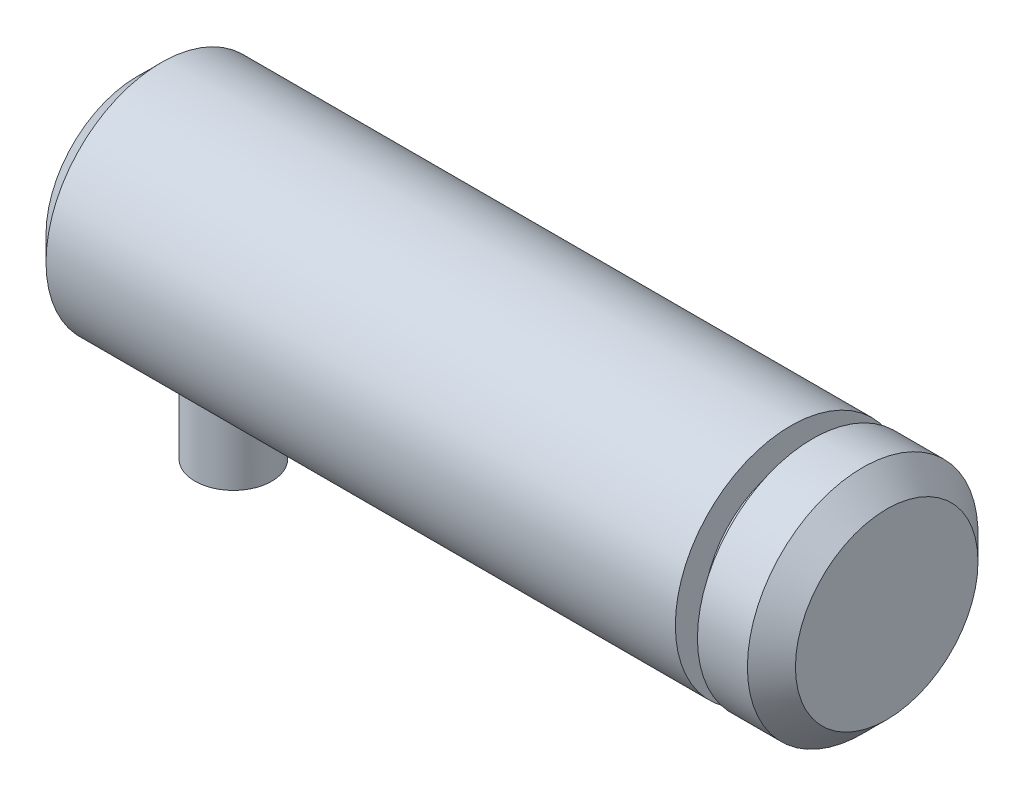
from build123d import *

# Parameters (mm, degrees)
SKETCH1_W           = 34
SKETCH1_H           = 6
SKETCH3_R           = 2
BOSS_EXTRUDE1_DEPTH = 10
SKETCH4_W           = 5
SKETCH4_H           = 6
SKETCH5_W           = 1.15
SKETCH5_H           = 1.5


with BuildPart() as part:
    # Sketch1 → Revolve1 (revolve)
    with BuildSketch(Plane.XY):
        with Locations((-2.5, 3)):
            Rectangle(SKETCH1_W, SKETCH1_H)
    revolve(axis=Axis((14.5, 0, 0), (-1, 0, 0)))

    # Sketch2 → Cut-Revolve1 (revolve, cut)
    with BuildSketch(Plane.XY):
        Polygon((-19.5, 4.75), (-18.25, 6), (-19.5, 6), align=None)
    revolve(axis=Axis((29, 0, 0), (-1, 0, 0)), mode=Mode.SUBTRACT)

    # Sketch3 → Boss-Extrude1 (add)
    with BuildSketch(Plane(origin=(0, 0, 0), x_dir=(1, 0, 0), z_dir=(0, 1, 0))):
        with Locations((-14.5, 0)):
            Circle(SKETCH3_R)
    extrude(amount=-BOSS_EXTRUDE1_DEPTH)

    # Sketch4 → Revolve2 (revolve)
    with BuildSketch(Plane.XY):
        with Locations((17, 3)):
            Rectangle(SKETCH4_W, SKETCH4_H)
    revolve(axis=Axis((19.5, 0, 0), (-1, 0, 0)))

    # Sketch5 → Cut-Revolve2 (revolve, cut)
    with BuildSketch(Plane.XY):
        with Locations((15.075, 5.25)):
            Rectangle(SKETCH5_W, SKETCH5_H)
    revolve(axis=Axis((29, 0, 0), (-1, 0, 0)), mode=Mode.SUBTRACT)

    # Sketch6 → Cut-Revolve3 (revolve, cut)
    with BuildSketch(Plane.XY):
        Polygon((18.25, 6), (19.5, 4.75), (19.5, 6), align=None)
    revolve(axis=Axis((29, 0, 0), (-1, 0, 0)), mode=Mode.SUBTRACT)


solid = part.part
